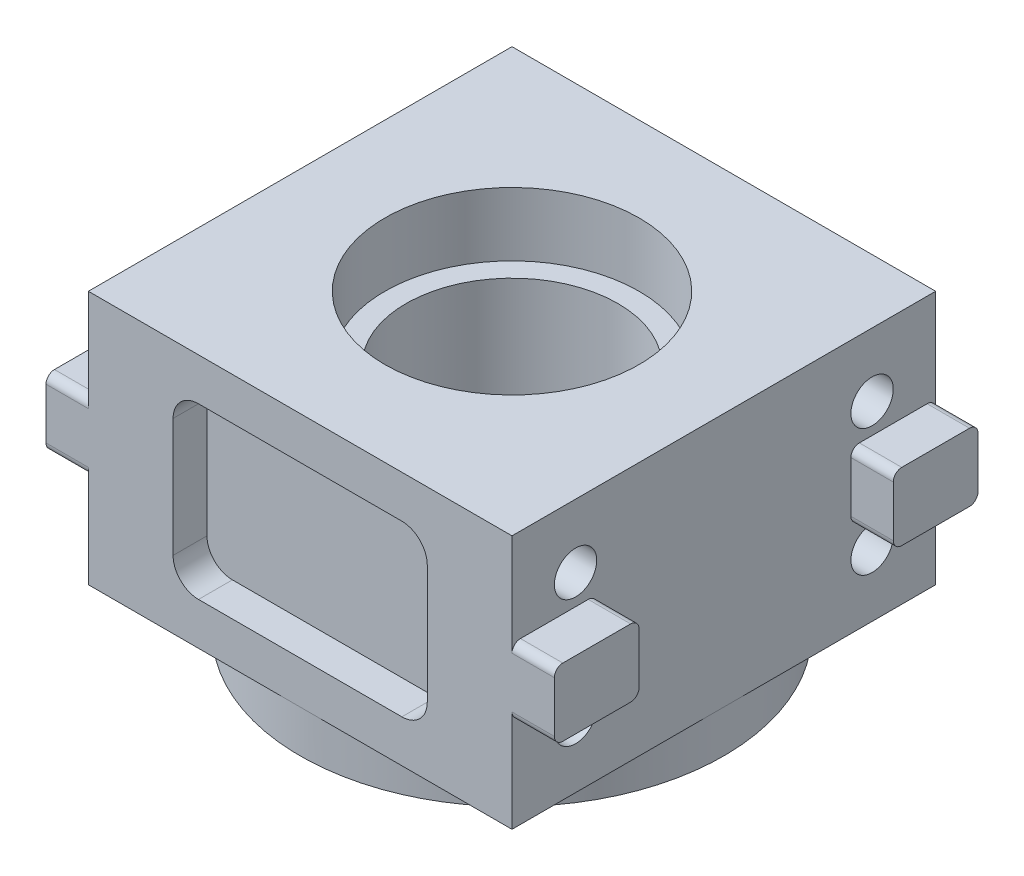
from build123d import *

# Parameters (mm, degrees)
SKETCH1_W                = 127
SKETCH1_H                = 127
SKETCH1_R                = 38.1
BOSS_EXTRUDE1_DEPTH      = 76.2
SKETCH2_R                = 6.35
CUT_EXTRUDE1_DEPTH       = 25.4
SKETCH3_R                = 63.5
SKETCH3_R_2              = 38.1
BOSS_EXTRUDE2_DEPTH      = 12.7
SKETCH4_W                = 12.7
SKETCH4_H                = 20.32
BOSS_EXTRUDE3_DEPTH      = 25.4
FILLET1_R                = 2.54
FILLET1_OF_MIRROR2_R     = 2.54
SKETCH5_W                = 76.2
SKETCH5_H                = 50.8
CUT_EXTRUDE3_DEPTH       = 10.16
FILLET2_R                = 7.62
SKETCH6_R                = 38.1
SKETCH6_R_2              = 31.75
BOSS_EXTRUDE4_DEPTH      = 25.4
BOSS_EXTRUDE4_DEPTH_BACK = 25.4


with BuildPart() as part:
    # Sketch1 → Boss-Extrude1 (new body)
    with BuildSketch(Plane(origin=(0, 0, 0), x_dir=(1, 0, 0), z_dir=(0, 1, 0))):
        Rectangle(SKETCH1_W, SKETCH1_H)
        Circle(SKETCH1_R, mode=Mode.SUBTRACT)
    extrude(amount=BOSS_EXTRUDE1_DEPTH)

    # Sketch2 → Cut-Extrude1 (cut)
    with BuildSketch(Plane.ZY.offset(63.5)):
        with Locations((-44.45, 57.15)):
            Circle(SKETCH2_R)
        with Locations((-44.45, 19.05)):
            Circle(SKETCH2_R)
        with Locations((44.45, 57.15)):
            Circle(SKETCH2_R)
        with Locations((44.45, 19.05)):
            Circle(SKETCH2_R)
    cut_extrude1 = extrude(amount=-CUT_EXTRUDE1_DEPTH, mode=Mode.SUBTRACT)

    # Mirror1: Cut-Extrude1 across plane
    add(cut_extrude1.mirror(Plane(origin=(0, 0, 0), x_dir=(0, 0, 1), z_dir=(1, 0, 0))), mode=Mode.SUBTRACT)

    # Sketch3 → Boss-Extrude2 (add)
    with BuildSketch(Plane.XZ):
        Circle(SKETCH3_R)
        Circle(SKETCH3_R_2, mode=Mode.SUBTRACT)
    extrude(amount=BOSS_EXTRUDE2_DEPTH)

    # Sketch4 → Boss-Extrude3 (add)
    with BuildSketch(Plane.XY.offset(63.5)):
        with Locations((-69.85, 38.1)):
            Rectangle(SKETCH4_W, SKETCH4_H)
        with Locations((69.85, 38.1)):
            Rectangle(SKETCH4_W, SKETCH4_H)
    boss_extrude3 = extrude(amount=-BOSS_EXTRUDE3_DEPTH)

    # Fillet1
    fillet1_edges = [part.edges().sort_by_distance(p)[0] for p in [
        (-69.85, 27.94, 38.1),
        (-69.85, 48.26, 38.1),
        (-69.85, 48.26, 63.5),
        (-69.85, 27.94, 63.5),
        (69.85, 48.26, 38.1),
        (69.85, 27.94, 38.1),
        (69.85, 27.94, 63.5),
        (69.85, 48.26, 63.5),
    ]]
    fillet(fillet1_edges, radius=FILLET1_R)

    # Mirror2: Boss-Extrude3 across plane
    add(boss_extrude3.mirror(Plane.XY))

    # Fillet1 of Mirror2
    fillet1_of_mirror2_edges = [part.edges().sort_by_distance(p)[0] for p in [
        (-69.85, 27.94, -38.1),
        (-69.85, 48.26, -38.1),
        (-69.85, 48.26, -63.5),
        (-69.85, 27.94, -63.5),
        (69.85, 48.26, -38.1),
        (69.85, 27.94, -38.1),
        (69.85, 27.94, -63.5),
        (69.85, 48.26, -63.5),
    ]]
    fillet(fillet1_of_mirror2_edges, radius=FILLET1_OF_MIRROR2_R)

    # Sketch5 → Cut-Extrude3 (cut)
    with BuildSketch(Plane(origin=(0, 0, 63.5), x_dir=(-1, 0, 0), z_dir=(0, 0, -1))):
        with Locations((0, 38.1)):
            Rectangle(SKETCH5_W, SKETCH5_H)
    extrude(amount=CUT_EXTRUDE3_DEPTH, mode=Mode.SUBTRACT)

    # Fillet2
    fillet2_edges = [part.edges().sort_by_distance(p)[0] for p in [
        (38.1, 63.5, 58.42),
        (38.1, 12.7, 58.42),
        (-38.1, 12.7, 58.42),
        (-38.1, 63.5, 58.42),
    ]]
    fillet(fillet2_edges, radius=FILLET2_R)

    # Sketch6 → Boss-Extrude4 (add, two sides)
    with BuildSketch(Plane(origin=(0, 31.75, 0), x_dir=(-1, 0, 0), z_dir=(0, -1, 0))) as boss_extrude4_sk:
        Circle(SKETCH6_R)
        Circle(SKETCH6_R_2, mode=Mode.SUBTRACT)
    extrude(amount=BOSS_EXTRUDE4_DEPTH)
    extrude(boss_extrude4_sk.sketch, amount=-BOSS_EXTRUDE4_DEPTH_BACK)


solid = part.part
